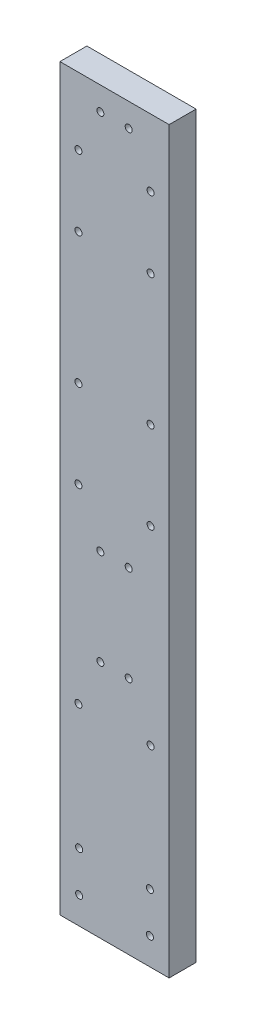
from build123d import *

# Parameters (mm, degrees)
SKETCH1_W           = 16.2
SKETCH1_H           = 109.64
SKETCH1_R           = 0.519960121
BOSS_EXTRUDE1_DEPTH = 4


with BuildPart() as part:
    # Sketch1 → Boss-Extrude1 (new body)
    with BuildSketch(Plane.XY):
        with Locations((8.1, 54.82)):
            Rectangle(SKETCH1_W, SKETCH1_H)
        with Locations((13.45, 56.71)):
            Circle(SKETCH1_R, mode=Mode.SUBTRACT)
        with Locations((10.2, 49.71)):
            Circle(SKETCH1_R, mode=Mode.SUBTRACT)
        with Locations((10.2, 106.16)):
            Circle(SKETCH1_R, mode=Mode.SUBTRACT)
        with Locations((2.75, 99.66)):
            Circle(SKETCH1_R, mode=Mode.SUBTRACT)
        with Locations((6, 49.71)):
            Circle(SKETCH1_R, mode=Mode.SUBTRACT)
        with Locations((2.75, 28.5)):
            Circle(SKETCH1_R, mode=Mode.SUBTRACT)
        with Locations((2.75, 89.16)):
            Circle(SKETCH1_R, mode=Mode.SUBTRACT)
        with Locations((2.75, 56.71)):
            Circle(SKETCH1_R, mode=Mode.SUBTRACT)
        with Locations((13.45, 89.16)):
            Circle(SKETCH1_R, mode=Mode.SUBTRACT)
        with Locations((13.45, 99.66)):
            Circle(SKETCH1_R, mode=Mode.SUBTRACT)
        with Locations((13.45, 69.71)):
            Circle(SKETCH1_R, mode=Mode.SUBTRACT)
        with Locations((6, 35.5)):
            Circle(SKETCH1_R, mode=Mode.SUBTRACT)
        with Locations((6, 106.16)):
            Circle(SKETCH1_R, mode=Mode.SUBTRACT)
        with Locations((10.2, 35.5)):
            Circle(SKETCH1_R, mode=Mode.SUBTRACT)
        with Locations((2.75, 69.71)):
            Circle(SKETCH1_R, mode=Mode.SUBTRACT)
        with Locations((13.45, 28.5)):
            Circle(SKETCH1_R, mode=Mode.SUBTRACT)
        with Locations((2.85, 10)):
            Circle(SKETCH1_R, mode=Mode.SUBTRACT)
        with Locations((13.35, 10)):
            Circle(SKETCH1_R, mode=Mode.SUBTRACT)
        with Locations((13.35, 4)):
            Circle(SKETCH1_R, mode=Mode.SUBTRACT)
        with Locations((2.85, 4)):
            Circle(SKETCH1_R, mode=Mode.SUBTRACT)
    extrude(amount=BOSS_EXTRUDE1_DEPTH)


solid = part.part
